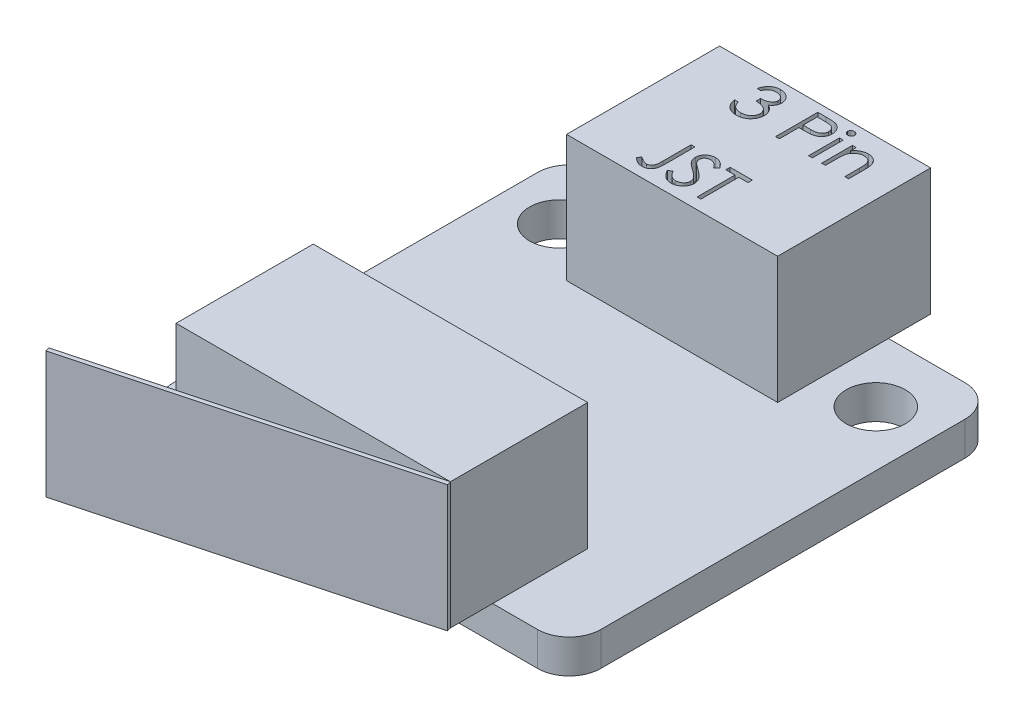
from build123d import *

# Parameters (mm, degrees)
SKETCH1_R           = 1.4
BOSS_EXTRUDE1_DEPTH = 1.6
SKETCH2_W           = 13
SKETCH2_H           = 4.5
SKETCH2_W_2         = 10
SKETCH2_H_2         = 2
SKETCH2_H_3         = 5.25
BOSS_EXTRUDE2_DEPTH = 6
SKETCH3_W           = 0.17948718
SKETCH3_H           = 1.461538462
CUT_EXTRUDE1_DEPTH  = 1


with BuildPart() as part:
    # Sketch1 → Boss-Extrude1 (new body)
    with BuildSketch(Plane(origin=(0, 0, 0), x_dir=(1, 0, 0), z_dir=(0, 1, 0))):
        with BuildLine():
            Line((-8.625, -10.125), (8.625, -10.125))
            ThreePointArc((8.625, -10.125), (9.685660172, -9.685660172), (10.125, -8.625))
            Line((10.125, -8.625), (10.125, 8.625))
            ThreePointArc((10.125, 8.625), (9.685660172, 9.685660172), (8.625, 10.125))
            Line((8.625, 10.125), (-8.625, 10.125))
            ThreePointArc((-8.625, 10.125), (-9.685660172, 9.685660172), (-10.125, 8.625))
            Line((-10.125, 8.625), (-10.125, -8.625))
            ThreePointArc((-10.125, -8.625), (-9.685660172, -9.685660172), (-8.625, -10.125))
        make_face()
        with Locations((-7.5, 7.025)):
            Circle(SKETCH1_R, mode=Mode.SUBTRACT)
        with Locations((7.5, 7.025)):
            Circle(SKETCH1_R, mode=Mode.SUBTRACT)
    extrude(amount=BOSS_EXTRUDE1_DEPTH)

    # Sketch2 → Boss-Extrude2 (add)
    with BuildSketch(Plane(origin=(0, 1.6, 0), x_dir=(1, 0, 0), z_dir=(0, 1, 0))):
        with Locations((0, -7.875)):
            Rectangle(SKETCH2_W, SKETCH2_H)
        with Locations((0, 11.125)):
            Rectangle(SKETCH2_W_2, SKETCH2_H_2)
        with Locations((0, 7.5)):
            Rectangle(SKETCH2_W_2, SKETCH2_H_3)
        with Locations((0, -11.125)):
            Rectangle(SKETCH2_W, SKETCH2_H_2)
        Polygon((-8.448236191, -16.337423052), (6.551763809, -12.318185165), (6.5, -12.125), (-8.5, -16.144237886), align=None)
    extrude(amount=BOSS_EXTRUDE2_DEPTH)

    # Sketch3 → Cut-Extrude1 (cut)
    with BuildSketch(Plane(origin=(0, 7.6, 0), x_dir=(1, 0, 0), z_dir=(0, 1, 0))):
        with BuildLine():
            Line((-2.186584499, 11.272188245), (-2.366071678, 11.272188245))
            add(Edge.make_bspline(
                [(-2.366071678, 11.272188245), (-2.361209078, 11.292321093), (-2.351703092, 11.331679164), (-2.331875907, 11.387911884), (-2.310276333, 11.441125325), (-2.284339701, 11.490323081), (-2.256048985, 11.536493883), (-2.223636001, 11.578590526), (-2.188596159, 11.617683649), (-2.149839046, 11.652376927), (-2.109194096, 11.683792773), (-2.066088599, 11.71057852), (-2.021389803, 11.733620893), (-1.974788012, 11.752603882), (-1.926144486, 11.766904182), (-1.875898987, 11.777279499), (-1.823919844, 11.784017279), (-1.788635506, 11.784674857), (-1.770719114, 11.785008758)],
                knots=[0, 0, 0, 0, 6.2094e-05, 0.000121389, 0.000178681, 0.000234231, 0.000288038, 0.000340924, 0.000393396, 0.000445302, 0.000496746, 0.000547326, 0.000597318, 0.000647462, 0.000698039, 0.000749191, 0.00080127, 0.000854993, 0.000854993, 0.000854993, 0.000854993], degree=3))
            add(Edge.make_bspline(
                [(-1.770719114, 11.785008758), (-1.74461469, 11.784220626), (-1.692975255, 11.782661554), (-1.617110657, 11.768424733), (-1.543952475, 11.745896086), (-1.474301476, 11.714768242), (-1.409605229, 11.676375492), (-1.352041693, 11.630681357), (-1.302391116, 11.57856747), (-1.260737186, 11.521006005), (-1.228122901, 11.459488571), (-1.204073544, 11.396174195), (-1.189432584, 11.331213069), (-1.187535123, 11.287351766), (-1.186584499, 11.265377347)],
                knots=[0, 0, 0, 0, 7.8249e-05, 0.000154792, 0.000230699, 0.00030746, 0.000383109, 0.000455815, 0.000527226, 0.000598392, 0.000668292, 0.000735487, 0.000801106, 0.000866986, 0.000866986, 0.000866986, 0.000866986], degree=3))
            add(Edge.make_bspline(
                [(-1.186584499, 11.265377347), (-1.187249408, 11.244230607), (-1.188550532, 11.202849719), (-1.199598364, 11.142437435), (-1.218190514, 11.085499378), (-1.243944664, 11.031795857), (-1.277282693, 10.981667377), (-1.317667091, 10.935001153), (-1.365382898, 10.891590206), (-1.401542291, 10.866721936), (-1.420158217, 10.853919014)],
                knots=[0, 0, 0, 0, 6.3404e-05, 0.000124072, 0.000183492, 0.000242626, 0.000302185, 0.000363545, 0.000427363, 0.000495082, 0.000495082, 0.000495082, 0.000495082], degree=3))
            add(Edge.make_bspline(
                [(-1.420158217, 10.853919014), (-1.398882928, 10.843645773), (-1.356730429, 10.823291512), (-1.299272983, 10.783373936), (-1.247114197, 10.737284594), (-1.218026358, 10.701317364), (-1.203411422, 10.683245937)],
                knots=[0, 0, 0, 0, 7.0779e-05, 0.000140233, 0.000209172, 0.000278788, 0.000278788, 0.000278788, 0.000278788], degree=3))
            add(Edge.make_bspline(
                [(-1.203411422, 10.683245937), (-1.193787798, 10.670070079), (-1.174698143, 10.643934127), (-1.151134981, 10.601913312), (-1.129758344, 10.559426747), (-1.113101076, 10.515335657), (-1.100201723, 10.470151078), (-1.090981133, 10.423795423), (-1.085253053, 10.376230839), (-1.084432737, 10.344052279), (-1.084020396, 10.327877347)],
                knots=[0, 0, 0, 0, 4.8904e-05, 9.7008e-05, 0.000144311, 0.000191485, 0.000238152, 0.000285138, 0.000333143, 0.000381662, 0.000381662, 0.000381662, 0.000381662], degree=3))
            add(Edge.make_bspline(
                [(-1.084020396, 10.327877347), (-1.085045832, 10.299871792), (-1.087091879, 10.243992477), (-1.105379922, 10.161435493), (-1.133730345, 10.080735206), (-1.173991451, 10.003549584), (-1.223058599, 9.931332223), (-1.281434213, 9.866717189), (-1.348455018, 9.81117513), (-1.423201103, 9.764769285), (-1.504182319, 9.72767333), (-1.590796943, 9.701926219), (-1.681796974, 9.685157077), (-1.744201144, 9.683358866), (-1.775927447, 9.682444655)],
                knots=[0, 0, 0, 0, 8.3922e-05, 0.000167448, 0.000252476, 0.000339918, 0.00042782, 0.000513763, 0.00060025, 0.000688074, 0.000777001, 0.000866606, 0.000958558, 0.001053653, 0.001053653, 0.001053653, 0.001053653], degree=3))
            add(Edge.make_bspline(
                [(-1.775927447, 9.682444655), (-1.797309905, 9.682940777), (-1.83938345, 9.683916979), (-1.901236878, 9.690590466), (-1.960277849, 9.70277904), (-2.016586191, 9.719180929), (-2.070211926, 9.73997621), (-2.120991415, 9.765872609), (-2.169237068, 9.796336324), (-2.214493612, 9.831726946), (-2.25675565, 9.871316283), (-2.294900064, 9.915807146), (-2.329562803, 9.964377091), (-2.359815739, 10.017590266), (-2.387036855, 10.074758984), (-2.409425973, 10.136615269), (-2.429132012, 10.202606139), (-2.438293992, 10.248593419), (-2.442994755, 10.272188245)],
                knots=[0, 0, 0, 0, 6.4148e-05, 0.000126221, 0.000186329, 0.000244775, 0.000301988, 0.000358608, 0.000415515, 0.000472897, 0.000530714, 0.000588945, 0.00064842, 0.000709443, 0.000772349, 0.000838139, 0.0009066, 0.000978738, 0.000978738, 0.000978738, 0.000978738], degree=3))
            Line((-2.442994755, 10.272188245), (-2.263507576, 10.272188245))
            add(Edge.make_bspline(
                [(-2.263507576, 10.272188245), (-2.258831409, 10.256788809), (-2.249735859, 10.226835568), (-2.234253403, 10.183726822), (-2.21661439, 10.144207934), (-2.197691785, 10.107989007), (-2.177818388, 10.074713349), (-2.155581288, 10.045260852), (-2.13262749, 10.018337879), (-2.115325003, 10.00316953), (-2.106856935, 9.995745937)],
                knots=[0, 0, 0, 0, 4.8278e-05, 9.3906e-05, 0.00013731, 0.000177989, 0.000216467, 0.000253406, 0.000288608, 0.00032235, 0.00032235, 0.00032235, 0.00032235], degree=3))
            add(Edge.make_bspline(
                [(-2.106856935, 9.995745937), (-2.095658891, 9.987112603), (-2.073297369, 9.969872585), (-2.03685838, 9.947871655), (-1.998535588, 9.928808212), (-1.957498631, 9.9142461), (-1.914633048, 9.901916008), (-1.869245982, 9.89384714), (-1.821737858, 9.888311042), (-1.789299136, 9.88782251), (-1.772722319, 9.88757286)],
                knots=[0, 0, 0, 0, 4.2389e-05, 8.4646e-05, 0.00012747, 0.000170564, 0.000215086, 0.000261134, 0.000308695, 0.000358401, 0.000358401, 0.000358401, 0.000358401], degree=3))
            add(Edge.make_bspline(
                [(-1.772722319, 9.88757286), (-1.754006032, 9.887924806), (-1.717407948, 9.888613006), (-1.664005171, 9.894941981), (-1.613200916, 9.90415936), (-1.565559244, 9.91839535), (-1.520456097, 9.935984408), (-1.478523725, 9.958069211), (-1.439211665, 9.983980481), (-1.403023433, 10.013431429), (-1.370483143, 10.045672283), (-1.341831993, 10.079394038), (-1.317475043, 10.114454512), (-1.297827284, 10.151047724), (-1.282312684, 10.18902214), (-1.271750855, 10.228484329), (-1.264407132, 10.269111338), (-1.263809068, 10.296727892), (-1.263507576, 10.310649783)],
                knots=[0, 0, 0, 0, 5.6126e-05, 0.000109749, 0.000161137, 0.000210833, 0.00025867, 0.000306159, 0.000352718, 0.000399709, 0.000445888, 0.000489953, 0.000532294, 0.000573701, 0.000614323, 0.000655048, 0.000696082, 0.000737797, 0.000737797, 0.000737797, 0.000737797], degree=3))
            add(Edge.make_bspline(
                [(-1.263507576, 10.310649783), (-1.264382034, 10.329284834), (-1.266126598, 10.36646221), (-1.279445787, 10.421157967), (-1.301353709, 10.47385706), (-1.332023716, 10.523660368), (-1.369358418, 10.569818026), (-1.412995507, 10.611001731), (-1.463297352, 10.64498464), (-1.50959442, 10.668463872), (-1.550603081, 10.684485058), (-1.585697586, 10.695156466), (-1.624987074, 10.704192841), (-1.667996416, 10.712599853), (-1.715049683, 10.719754909), (-1.766095647, 10.725721661), (-1.821144654, 10.73049597), (-1.859253892, 10.732628024), (-1.878892191, 10.733726706)],
                knots=[0, 0, 0, 0, 5.5863e-05, 0.000111448, 0.000167846, 0.000226457, 0.000286274, 0.000345516, 0.000405747, 0.000467742, 0.00050085, 0.000537728, 0.000577668, 0.000621748, 0.000669174, 0.000720409, 0.000775906, 0.000834911, 0.000834911, 0.000834911, 0.000834911], degree=3))
            Line((-1.878892191, 10.733726706), (-1.878892191, 10.938854911))
            add(Edge.make_bspline(
                [(-1.878892191, 10.938854911), (-1.854148668, 10.939274799), (-1.805682184, 10.940097256), (-1.734885438, 10.950044691), (-1.667186403, 10.96380505), (-1.604085407, 10.984882302), (-1.546571857, 11.009362472), (-1.496674942, 11.037849449), (-1.455093715, 11.06951502), (-1.422030245, 11.10484794), (-1.3971564, 11.142742252), (-1.378969659, 11.182237485), (-1.368226615, 11.223679806), (-1.36679252, 11.251962473), (-1.366071678, 11.266178629)],
                knots=[0, 0, 0, 0, 7.4172e-05, 0.000145284, 0.00021412, 0.000281142, 0.000344481, 0.000401381, 0.000453069, 0.000500694, 0.000545808, 0.000588481, 0.000630653, 0.000673274, 0.000673274, 0.000673274, 0.000673274], degree=3))
            add(Edge.make_bspline(
                [(-1.366071678, 11.266178629), (-1.366308484, 11.276623055), (-1.366779599, 11.297401745), (-1.372720901, 11.327758927), (-1.381648924, 11.357188039), (-1.393923055, 11.385563931), (-1.41035174, 11.412689801), (-1.430012304, 11.438796915), (-1.453422647, 11.463736217), (-1.480248617, 11.486982114), (-1.509055362, 11.509135964), (-1.540626662, 11.527943757), (-1.574010591, 11.544026649), (-1.609244108, 11.557289222), (-1.646441554, 11.567265958), (-1.685428158, 11.574429296), (-1.726278263, 11.578907956), (-1.754147824, 11.579552765), (-1.768315268, 11.579880552)],
                knots=[0, 0, 0, 0, 3.1291e-05, 6.2252e-05, 9.2415e-05, 0.000123453, 0.000154716, 0.000187329, 0.000221343, 0.00025711, 0.000293729, 0.000330214, 0.000367127, 0.000404781, 0.000442976, 0.000482502, 0.000523604, 0.000566103, 0.000566103, 0.000566103, 0.000566103], degree=3))
            add(Edge.make_bspline(
                [(-1.768315268, 11.579880552), (-1.79108765, 11.579085488), (-1.835567408, 11.577532543), (-1.899690217, 11.563930821), (-1.959301265, 11.542229059), (-2.004866218, 11.516324477), (-2.038513403, 11.4907528), (-2.062557367, 11.468420008), (-2.086169088, 11.443601252), (-2.107795189, 11.414767895), (-2.129666033, 11.383872586), (-2.149577211, 11.349344768), (-2.168925606, 11.312085114), (-2.180584206, 11.285744751), (-2.186584499, 11.272188245)],
                knots=[0, 0, 0, 0, 6.8251e-05, 0.000133311, 0.000195677, 0.000257943, 0.000289675, 0.000322285, 0.000356299, 0.000392281, 0.000430289, 0.000469798, 0.000511728, 0.000556192, 0.000556192, 0.000556192, 0.000556192], degree=3))
        make_face()
        with BuildLine():
            Line((0.044184732, 11.733726706), (0.436412296, 11.733726706))
            add(Edge.make_bspline(
                [(0.436412296, 11.733726706), (0.463389957, 11.733697051), (0.515080353, 11.733640231), (0.589203242, 11.731917519), (0.656523088, 11.729616552), (0.716894735, 11.726426899), (0.770503933, 11.722657419), (0.817108105, 11.717370539), (0.857073565, 11.71185037), (0.881020108, 11.706238138), (0.891941142, 11.703678629)],
                knots=[0, 0, 0, 0, 8.093e-05, 0.000155066, 0.000222417, 0.000282999, 0.000336434, 0.000383598, 0.000423714, 0.000457349, 0.000457349, 0.000457349, 0.000457349], degree=3))
            add(Edge.make_bspline(
                [(0.891941142, 11.703678629), (0.905766019, 11.699894658), (0.933090006, 11.69241588), (0.97246203, 11.677436609), (1.009921371, 11.659675372), (1.045596547, 11.639433121), (1.079049166, 11.61584137), (1.110778332, 11.589856445), (1.140504035, 11.560878406), (1.168059116, 11.529232269), (1.193364715, 11.495449292), (1.215153105, 11.459025161), (1.233397235, 11.420572987), (1.249044818, 11.380119518), (1.260306792, 11.337325047), (1.268790735, 11.292486926), (1.274175665, 11.24560996), (1.274691415, 11.21357575), (1.274953963, 11.197268373)],
                knots=[0, 0, 0, 0, 4.2981e-05, 8.4949e-05, 0.000126168, 0.000167265, 0.000207832, 0.000248819, 0.000290184, 0.000332208, 0.000374596, 0.000416646, 0.000459295, 0.000502155, 0.00054657, 0.00059183, 0.000638993, 0.000687898, 0.000687898, 0.000687898, 0.000687898], degree=3))
            add(Edge.make_bspline(
                [(1.274953963, 11.197268373), (1.274713149, 11.180823929), (1.27424198, 11.148649264), (1.268586959, 11.101579099), (1.260969707, 11.056597162), (1.249257106, 11.01380319), (1.233916721, 10.973451321), (1.215921262, 10.934924903), (1.194216388, 10.898879376), (1.169276485, 10.865183881), (1.141532717, 10.833806788), (1.111102467, 10.804975477), (1.078108585, 10.778858712), (1.042655929, 10.755397944), (1.004398873, 10.735137213), (0.963917642, 10.716990182), (0.920860375, 10.701749576), (0.891064653, 10.693732398), (0.875915501, 10.689656193)],
                knots=[0, 0, 0, 0, 4.9305e-05, 9.6468e-05, 0.00014205, 0.000186079, 0.000229313, 0.000271428, 0.000313478, 0.000355306, 0.000397028, 0.000438971, 0.000480893, 0.000523119, 0.000566318, 0.000610617, 0.000656109, 0.000703161, 0.000703161, 0.000703161, 0.000703161], degree=3))
            add(Edge.make_bspline(
                [(0.875915501, 10.689656193), (0.863385596, 10.686991633), (0.835925581, 10.681152093), (0.790701168, 10.674632975), (0.738046662, 10.669068632), (0.67803393, 10.664896553), (0.610716842, 10.661324914), (0.53605898, 10.658486003), (0.453913793, 10.656926087), (0.39661594, 10.656845634), (0.366700758, 10.656803629)],
                knots=[0, 0, 0, 0, 3.8422e-05, 8.4204e-05, 0.000136987, 0.000197244, 0.000264648, 0.00033922, 0.000421367, 0.000511112, 0.000511112, 0.000511112, 0.000511112], degree=3))
            Line((0.366700758, 10.656803629), (0.223671912, 10.656803629))
            Line((0.223671912, 10.656803629), (0.223671912, 9.733726706))
            Line((0.223671912, 9.733726706), (0.044184732, 9.733726706))
            Line((0.044184732, 9.733726706), (0.044184732, 11.733726706))
        make_face()
        with BuildLine():
            Line((0.223671912, 11.528598501), (0.223671912, 10.861931834))
            Line((0.223671912, 10.861931834), (0.573832168, 10.857524783))
            add(Edge.make_bspline(
                [(0.573832168, 10.857524783), (0.590929268, 10.857515947), (0.623934868, 10.857498888), (0.67161271, 10.859776159), (0.715846589, 10.862405035), (0.756500632, 10.866254134), (0.793593166, 10.871694852), (0.827186039, 10.877187274), (0.857018772, 10.885133196), (0.891932602, 10.895832092), (0.930837372, 10.914079301), (0.973161685, 10.940564953), (1.009030592, 10.974325357), (1.040069619, 11.012284118), (1.064701549, 11.054512192), (1.082733545, 11.099694442), (1.093328492, 11.147367499), (1.094749174, 11.179989292), (1.095466783, 11.196467091)],
                knots=[0, 0, 0, 0, 5.1284e-05, 9.9002e-05, 0.000143162, 0.000184223, 0.000221448, 0.000255634, 0.000286243, 0.000313992, 0.000365087, 0.000414652, 0.000463136, 0.000512129, 0.000561328, 0.000609166, 0.000657575, 0.000706986, 0.000706986, 0.000706986, 0.000706986], degree=3))
            add(Edge.make_bspline(
                [(1.095466783, 11.196467091), (1.094745271, 11.212546241), (1.093310994, 11.244509603), (1.082650501, 11.291354609), (1.064736607, 11.336060725), (1.039904267, 11.377759631), (1.009766479, 11.415581805), (0.974738283, 11.448437306), (0.934902133, 11.474849708), (0.897846001, 11.491897297), (0.864931038, 11.502306026), (0.836341347, 11.509588792), (0.804060961, 11.515403424), (0.768079373, 11.520111712), (0.728675468, 11.524142261), (0.685510716, 11.526877105), (0.638748635, 11.528477937), (0.606285451, 11.52855734), (0.589457168, 11.528598501)],
                knots=[0, 0, 0, 0, 4.8212e-05, 9.5839e-05, 0.000143305, 0.000192158, 0.0002409, 0.000287958, 0.000335627, 0.000383673, 0.000409773, 0.000439118, 0.000472122, 0.000508102, 0.000547967, 0.000590927, 0.00063783, 0.000688312, 0.000688312, 0.000688312, 0.000688312], degree=3))
            Line((0.589457168, 11.528598501), (0.223671912, 11.528598501))
        make_face(mode=Mode.SUBTRACT)
        with BuildLine():
            add(Edge.make_bspline(
                [(1.697229604, 11.810649783), (1.708367499, 11.810133125), (1.730177636, 11.809121408), (1.761716646, 11.800457707), (1.790434938, 11.785772172), (1.815907929, 11.766069498), (1.83776615, 11.742898387), (1.853069413, 11.715892119), (1.862905068, 11.686715754), (1.864092813, 11.666364275), (1.864697553, 11.656002347)],
                knots=[0, 0, 0, 0, 3.3371e-05, 6.5347e-05, 9.724e-05, 0.000129534, 0.000161577, 0.000192089, 0.00022199, 0.000253006, 0.000253006, 0.000253006, 0.000253006], degree=3))
            add(Edge.make_bspline(
                [(1.864697553, 11.656002347), (1.864079176, 11.645909403), (1.862856717, 11.625956845), (1.85307701, 11.59728629), (1.837635731, 11.570655271), (1.815921945, 11.547529151), (1.790431224, 11.527837368), (1.761717632, 11.513148946), (1.730177376, 11.50448601), (1.708367411, 11.503474188), (1.697229604, 11.502957475)],
                knots=[0, 0, 0, 0, 3.0219e-05, 5.9738e-05, 8.9904e-05, 0.000121948, 0.000154241, 0.000186134, 0.00021811, 0.000251481, 0.000251481, 0.000251481, 0.000251481], degree=3))
            add(Edge.make_bspline(
                [(1.697229604, 11.502957475), (1.686219161, 11.503454458), (1.664788772, 11.504421771), (1.633722005, 11.513318924), (1.605248583, 11.527842394), (1.579725913, 11.547400214), (1.558451517, 11.570797298), (1.542966759, 11.597270038), (1.533209638, 11.625960983), (1.531984136, 11.645910793), (1.531364219, 11.656002347)],
                knots=[0, 0, 0, 0, 3.2972e-05, 6.4176e-05, 9.6069e-05, 0.000128362, 0.000160137, 0.000190302, 0.000219822, 0.000250041, 0.000250041, 0.000250041, 0.000250041], degree=3))
            add(Edge.make_bspline(
                [(1.531364219, 11.656002347), (1.531970554, 11.666362833), (1.533161435, 11.68671148), (1.542974073, 11.715908642), (1.558322534, 11.742755214), (1.579739999, 11.766198357), (1.605244834, 11.785767176), (1.633722974, 11.800287737), (1.664788516, 11.809185646), (1.686219074, 11.810152854), (1.697229604, 11.810649783)],
                knots=[0, 0, 0, 0, 3.1015e-05, 6.0916e-05, 9.1428e-05, 0.000123203, 0.000155496, 0.000187389, 0.000218593, 0.000251565, 0.000251565, 0.000251565, 0.000251565], degree=3))
        make_face()
        with Locations((1.698030886, 10.464495937)):
            Rectangle(SKETCH3_W, SKETCH3_H)
        with BuildLine():
            Line((2.223671912, 11.195265168), (2.403159091, 11.195265168))
            Line((2.403159091, 11.195265168), (2.403159091, 10.931643373))
            add(Edge.make_bspline(
                [(2.403159091, 10.931643373), (2.422323454, 10.9555535), (2.459512569, 11.001951937), (2.521446474, 11.062935122), (2.586900131, 11.113189536), (2.655472704, 11.153248847), (2.727257282, 11.183446919), (2.801816293, 11.205256023), (2.879596125, 11.218333068), (2.932490089, 11.220041771), (2.959248835, 11.220906193)],
                knots=[0, 0, 0, 0, 9.1873e-05, 0.000178282, 0.000260017, 0.000338833, 0.00041585, 0.000493062, 0.000571441, 0.00065169, 0.00065169, 0.00065169, 0.00065169], degree=3))
            add(Edge.make_bspline(
                [(2.959248835, 11.220906193), (2.986294911, 11.219908939), (3.039230607, 11.217957071), (3.116303785, 11.202518962), (3.188288581, 11.176150245), (3.254928328, 11.140029062), (3.315001021, 11.095111077), (3.367758079, 11.042780916), (3.41139422, 10.982588868), (3.440649856, 10.926747065), (3.459921655, 10.877210611), (3.472054419, 10.834783897), (3.482357837, 10.787516382), (3.491290265, 10.735550902), (3.497334329, 10.678523365), (3.502101352, 10.616667541), (3.505517749, 10.550003466), (3.505653296, 10.503896822), (3.505723194, 10.480120937)],
                knots=[0, 0, 0, 0, 8.1097e-05, 0.000158726, 0.000234646, 0.000310299, 0.000385299, 0.000458956, 0.000532359, 0.000607446, 0.0006474, 0.000691647, 0.000739665, 0.000792489, 0.00084974, 0.000911626, 0.00097861, 0.001049928, 0.001049928, 0.001049928, 0.001049928], degree=3))
            Line((3.505723194, 10.480120937), (3.505723194, 9.733726706))
            Line((3.505723194, 9.733726706), (3.326236014, 9.733726706))
            Line((3.326236014, 9.733726706), (3.326236014, 10.421226706))
            add(Edge.make_bspline(
                [(3.326236014, 10.421226706), (3.32612561, 10.441125246), (3.325914424, 10.479187767), (3.325248341, 10.533684351), (3.323642737, 10.583105253), (3.321386558, 10.62733232), (3.318084255, 10.666323084), (3.314642751, 10.700156957), (3.310434193, 10.728790981), (3.306683957, 10.746028171), (3.30500204, 10.753758758)],
                knots=[0, 0, 0, 0, 5.9697e-05, 0.00011419, 0.000163495, 0.000208031, 0.000247025, 0.000280871, 0.000310052, 0.000333782, 0.000333782, 0.000333782, 0.000333782], degree=3))
            add(Edge.make_bspline(
                [(3.30500204, 10.753758758), (3.298930307, 10.776450863), (3.287244101, 10.820126146), (3.25836754, 10.879368633), (3.221902293, 10.929767598), (3.177389237, 10.971011438), (3.125258336, 11.003109059), (3.065654255, 11.025379891), (2.999152174, 11.039309187), (2.952378241, 11.04069612), (2.927998835, 11.041419014)],
                knots=[0, 0, 0, 0, 7.0341e-05, 0.000135384, 0.000196446, 0.000255981, 0.000316244, 0.000378893, 0.000445995, 0.000519045, 0.000519045, 0.000519045, 0.000519045], degree=3))
            add(Edge.make_bspline(
                [(2.927998835, 11.041419014), (2.913560158, 11.041147011), (2.884986391, 11.040608725), (2.842614978, 11.035207983), (2.801515451, 11.02637458), (2.761275331, 11.014449644), (2.722699449, 10.998071205), (2.684548426, 10.979482993), (2.648258846, 10.956312586), (2.613056905, 10.930489374), (2.580306729, 10.901872684), (2.549833393, 10.871675821), (2.52266881, 10.839518333), (2.498058138, 10.805918363), (2.476813416, 10.770414456), (2.458268795, 10.733349138), (2.442534112, 10.694673624), (2.434715431, 10.667830732), (2.430803322, 10.654399783)],
                knots=[0, 0, 0, 0, 4.3299e-05, 8.5687e-05, 0.000127884, 0.000169329, 0.000211366, 0.000253471, 0.000296491, 0.000340322, 0.000384344, 0.000426838, 0.000468903, 0.000510495, 0.000551652, 0.000592861, 0.000634747, 0.000676692, 0.000676692, 0.000676692, 0.000676692], degree=3))
            add(Edge.make_bspline(
                [(2.430803322, 10.654399783), (2.428552094, 10.644539667), (2.423651289, 10.62307471), (2.418358043, 10.587849328), (2.413553715, 10.547100771), (2.409532595, 10.500876589), (2.407072357, 10.449014947), (2.404389845, 10.391737325), (2.403413239, 10.328815332), (2.403246179, 10.28500865), (2.403159091, 10.262172219)],
                knots=[0, 0, 0, 0, 3.0333e-05, 6.6032e-05, 0.000106782, 0.000153428, 0.000205187, 0.000262529, 0.000325441, 0.000393952, 0.000393952, 0.000393952, 0.000393952], degree=3))
            Line((2.403159091, 10.262172219), (2.403159091, 9.733726706))
            Line((2.403159091, 9.733726706), (2.223671912, 9.733726706))
            Line((2.223671912, 9.733726706), (2.223671912, 11.195265168))
        make_face()
        with BuildLine():
            Line((-1.622481935, 7.400393373), (-1.442994755, 7.400393373))
            Line((-1.442994755, 7.400393373), (-1.442994755, 6.049832475))
            add(Edge.make_bspline(
                [(-1.442994755, 6.049832475), (-1.443174137, 6.024858092), (-1.443518573, 5.976904229), (-1.445412522, 5.907833431), (-1.448917366, 5.844764467), (-1.454023087, 5.787553926), (-1.460834649, 5.736381037), (-1.468629522, 5.690850399), (-1.478065407, 5.651342009), (-1.492274817, 5.606978948), (-1.515574216, 5.558325346), (-1.550641095, 5.505779545), (-1.594202693, 5.459817596), (-1.644660426, 5.419901754), (-1.702455297, 5.388097621), (-1.766397136, 5.365266091), (-1.836092329, 5.351339887), (-1.884434736, 5.349869084), (-1.909340909, 5.349111322)],
                knots=[0, 0, 0, 0, 7.4924e-05, 0.000143864, 0.000207267, 0.000264396, 0.000316129, 0.000362105, 0.000402917, 0.000437886, 0.000501687, 0.000564025, 0.000626665, 0.000690864, 0.000756317, 0.000823611, 0.000893855, 0.000968504, 0.000968504, 0.000968504, 0.000968504], degree=3))
            add(Edge.make_bspline(
                [(-1.909340909, 5.349111322), (-1.928745685, 5.349728813), (-1.96778938, 5.350971245), (-2.025898356, 5.361097938), (-2.083842343, 5.376707106), (-2.141928885, 5.399565732), (-2.201305594, 5.430654645), (-2.262776649, 5.471331683), (-2.327132759, 5.521521127), (-2.369523208, 5.55982841), (-2.391712704, 5.579880552)],
                knots=[0, 0, 0, 0, 5.8181e-05, 0.000117065, 0.000176449, 0.000237977, 0.000303921, 0.000377151, 0.000458813, 0.000548513, 0.000548513, 0.000548513, 0.000548513], degree=3))
            Line((-2.391712704, 5.579880552), (-2.285943473, 5.733726706))
            add(Edge.make_bspline(
                [(-2.285943473, 5.733726706), (-2.261541942, 5.716899623), (-2.21546867, 5.685127895), (-2.147751847, 5.644255552), (-2.087753474, 5.6092126), (-2.048506075, 5.591354155), (-2.030334499, 5.583085681)],
                knots=[0, 0, 0, 0, 8.8895e-05, 0.000167846, 0.000237269, 0.000297126, 0.000297126, 0.000297126, 0.000297126], degree=3))
            add(Edge.make_bspline(
                [(-2.030334499, 5.583085681), (-2.019314892, 5.578765991), (-1.99770299, 5.570294117), (-1.964660087, 5.560839318), (-1.93180578, 5.555672226), (-1.910024241, 5.554711465), (-1.899324883, 5.554239527)],
                knots=[0, 0, 0, 0, 3.5497e-05, 6.9617e-05, 0.00010288, 0.000134994, 0.000134994, 0.000134994, 0.000134994], degree=3))
            add(Edge.make_bspline(
                [(-1.899324883, 5.554239527), (-1.885506147, 5.554823947), (-1.858191601, 5.555979129), (-1.81849789, 5.566178715), (-1.780521872, 5.581746946), (-1.745624925, 5.604541971), (-1.713461846, 5.63164564), (-1.686923089, 5.664420502), (-1.664798949, 5.700743921), (-1.651484839, 5.735127609), (-1.643002112, 5.766485684), (-1.637618325, 5.795304618), (-1.632910519, 5.828996892), (-1.628806775, 5.86760272), (-1.626404221, 5.911199396), (-1.623708636, 5.959658906), (-1.622734201, 6.013103427), (-1.622568589, 6.050366829), (-1.622481935, 6.069864527)],
                knots=[0, 0, 0, 0, 4.139e-05, 8.1813e-05, 0.000122217, 0.000164006, 0.000206332, 0.000247883, 0.000289933, 0.000333456, 0.000357948, 0.000387334, 0.00042133, 0.000459999, 0.000503759, 0.000552296, 0.000605595, 0.00066409, 0.00066409, 0.00066409, 0.00066409], degree=3))
            Line((-1.622481935, 6.069864527), (-1.622481935, 7.400393373))
        make_face()
        with BuildLine():
            Line((-1.135302447, 5.786210681), (-0.966231935, 5.88757286))
            add(Edge.make_bspline(
                [(-0.966231935, 5.88757286), (-0.950507228, 5.861250354), (-0.920379296, 5.810817449), (-0.870121376, 5.742669998), (-0.818045427, 5.684748765), (-0.763765808, 5.637390704), (-0.707613838, 5.600105626), (-0.64922295, 5.57370435), (-0.588789915, 5.557238079), (-0.547662017, 5.555238029), (-0.52712937, 5.554239527)],
                knots=[0, 0, 0, 0, 9.1943e-05, 0.00017616, 0.000253587, 0.00032516, 0.000391722, 0.000455019, 0.000516726, 0.000578245, 0.000578245, 0.000578245, 0.000578245], degree=3))
            add(Edge.make_bspline(
                [(-0.52712937, 5.554239527), (-0.509594022, 5.554727911), (-0.474830151, 5.555696134), (-0.423651727, 5.564999449), (-0.37394784, 5.579292095), (-0.326742904, 5.599761198), (-0.282688267, 5.624526047), (-0.24405587, 5.654438149), (-0.210658091, 5.687927409), (-0.183338597, 5.725288926), (-0.162378577, 5.765470154), (-0.146268823, 5.806713555), (-0.137328781, 5.849667022), (-0.135982065, 5.878587287), (-0.135302447, 5.893181834)],
                knots=[0, 0, 0, 0, 5.2559e-05, 0.000104198, 0.000155544, 0.000207414, 0.000258201, 0.000306763, 0.000353508, 0.000399665, 0.000445008, 0.000489133, 0.000532114, 0.000575902, 0.000575902, 0.000575902, 0.000575902], degree=3))
            add(Edge.make_bspline(
                [(-0.135302447, 5.893181834), (-0.136144911, 5.909833749), (-0.137857515, 5.943684657), (-0.152332647, 5.993627315), (-0.175103645, 6.043051641), (-0.19611087, 6.073623793), (-0.207017191, 6.089495937)],
                knots=[0, 0, 0, 0, 4.9875e-05, 0.000101388, 0.000154805, 0.000212482, 0.000212482, 0.000212482, 0.000212482], degree=3))
            add(Edge.make_bspline(
                [(-0.207017191, 6.089495937), (-0.215971828, 6.100951265), (-0.234770967, 6.125000293), (-0.267089546, 6.16079757), (-0.30501304, 6.197722381), (-0.347243643, 6.237184699), (-0.395319693, 6.277349154), (-0.447735416, 6.320131027), (-0.50582905, 6.363903357), (-0.546571619, 6.393259109), (-0.567594114, 6.408406193)],
                knots=[0, 0, 0, 0, 4.3611e-05, 9.1556e-05, 0.000144533, 0.00020237, 0.000264903, 0.000332417, 0.000405335, 0.000483068, 0.000483068, 0.000483068, 0.000483068], degree=3))
            add(Edge.make_bspline(
                [(-0.567594114, 6.408406193), (-0.588636398, 6.423393958), (-0.628867641, 6.452049422), (-0.685129688, 6.494577584), (-0.73544081, 6.533459795), (-0.779577391, 6.569062088), (-0.817520018, 6.601389291), (-0.849567681, 6.63013097), (-0.874904, 6.656064434), (-0.888992903, 6.672888057), (-0.895318473, 6.68044145)],
                knots=[0, 0, 0, 0, 7.7499e-05, 0.000148172, 0.000211562, 0.000268251, 0.000318269, 0.000361092, 0.000397358, 0.000426908, 0.000426908, 0.000426908, 0.000426908], degree=3))
            add(Edge.make_bspline(
                [(-0.895318473, 6.68044145), (-0.904159927, 6.692213471), (-0.921547834, 6.71536473), (-0.944499837, 6.751550363), (-0.96400793, 6.788592229), (-0.979300692, 6.826589866), (-0.992178531, 6.865009825), (-1.000840206, 6.904353394), (-1.006263861, 6.944444033), (-1.006819282, 6.971423177), (-1.007097319, 6.984928629)],
                knots=[0, 0, 0, 0, 4.4154e-05, 8.6835e-05, 0.000128409, 0.000169553, 0.000209589, 0.000249829, 0.00029023, 0.000330726, 0.000330726, 0.000330726, 0.000330726], degree=3))
            add(Edge.make_bspline(
                [(-1.007097319, 6.984928629), (-1.006351485, 7.0060885), (-1.00487576, 7.047955965), (-0.992395464, 7.10911644), (-0.972696668, 7.167508678), (-0.945099589, 7.222554583), (-0.909523959, 7.272820858), (-0.868354831, 7.318885708), (-0.819319696, 7.357610612), (-0.765518197, 7.391446074), (-0.706628841, 7.41792946), (-0.644919753, 7.437907163), (-0.580292855, 7.449226739), (-0.536519635, 7.450851176), (-0.514308858, 7.451675424)],
                knots=[0, 0, 0, 0, 6.3428e-05, 0.0001255, 0.000186441, 0.000247897, 0.000309471, 0.000370729, 0.000432548, 0.00049625, 0.000560973, 0.00062572, 0.000690402, 0.000757029, 0.000757029, 0.000757029, 0.000757029], degree=3))
            add(Edge.make_bspline(
                [(-0.514308858, 7.451675424), (-0.4907408, 7.450862538), (-0.443871457, 7.449245965), (-0.374929048, 7.435190233), (-0.308551495, 7.411932707), (-0.255155344, 7.385539188), (-0.213365195, 7.359178379), (-0.181495062, 7.335167051), (-0.149199376, 7.307524131), (-0.11621763, 7.276175991), (-0.083108682, 7.24083499), (-0.049380995, 7.201743168), (-0.014955698, 7.159139422), (0.007190508, 7.128725421), (0.018543706, 7.113133758)],
                knots=[0, 0, 0, 0, 7.065e-05, 0.000140501, 0.000210062, 0.000281193, 0.00031865, 0.000358154, 0.000400784, 0.000446125, 0.00049459, 0.000545998, 0.000600997, 0.000658851, 0.000658851, 0.000658851, 0.000658851], degree=3))
            Line((0.018543706, 7.113133758), (-0.143715909, 6.990136963))
            add(Edge.make_bspline(
                [(-0.143715909, 6.990136963), (-0.153513585, 7.002759071), (-0.172381617, 7.027066302), (-0.201027038, 7.061107054), (-0.228026266, 7.092202185), (-0.254626494, 7.119210829), (-0.279422855, 7.143612048), (-0.303489736, 7.164503338), (-0.326480794, 7.182089393), (-0.355461886, 7.200857141), (-0.391872011, 7.219460857), (-0.43757746, 7.235203188), (-0.485341046, 7.244663223), (-0.517872264, 7.245914016), (-0.534340909, 7.246547219)],
                knots=[0, 0, 0, 0, 4.793e-05, 9.2302e-05, 0.000133459, 0.000171424, 0.000205991, 0.000237801, 0.000266968, 0.00029275, 0.000341307, 0.0003892, 0.000437365, 0.000486748, 0.000486748, 0.000486748, 0.000486748], degree=3))
            add(Edge.make_bspline(
                [(-0.534340909, 7.246547219), (-0.555001779, 7.245854819), (-0.59484432, 7.244519591), (-0.651410169, 7.229936742), (-0.702320984, 7.206975679), (-0.746065307, 7.174795692), (-0.782486436, 7.13666941), (-0.808832413, 7.092795779), (-0.82468965, 7.044348691), (-0.826624667, 7.010553459), (-0.82761014, 6.993342091)],
                knots=[0, 0, 0, 0, 6.1856e-05, 0.000119283, 0.00017396, 0.000228453, 0.000281174, 0.000331125, 0.000380792, 0.000432338, 0.000432338, 0.000432338, 0.000432338], degree=3))
            add(Edge.make_bspline(
                [(-0.82761014, 6.993342091), (-0.827385496, 6.98262696), (-0.826935841, 6.961179178), (-0.820664528, 6.929492651), (-0.812607769, 6.897886171), (-0.79984055, 6.866501838), (-0.782214663, 6.834790776), (-0.759068848, 6.802206926), (-0.729918384, 6.768463092), (-0.707588663, 6.746516022), (-0.695799242, 6.734928629)],
                knots=[0, 0, 0, 0, 3.2091e-05, 6.4235e-05, 9.6598e-05, 0.000129854, 0.000165538, 0.000205219, 0.000249544, 0.000299122, 0.000299122, 0.000299122, 0.000299122], degree=3))
            add(Edge.make_bspline(
                [(-0.695799242, 6.734928629), (-0.691421315, 6.731021757), (-0.681020363, 6.721739924), (-0.662005548, 6.706544335), (-0.636895377, 6.687799894), (-0.606345548, 6.664607142), (-0.56979277, 6.637703449), (-0.527233024, 6.607432813), (-0.479140719, 6.572812551), (-0.44501391, 6.548608242), (-0.426969114, 6.53581004)],
                knots=[0, 0, 0, 0, 1.7601e-05, 4.1816e-05, 7.2986e-05, 0.000111608, 0.000156882, 0.000209138, 0.000268286, 0.000334654, 0.000334654, 0.000334654, 0.000334654], degree=3))
            add(Edge.make_bspline(
                [(-0.426969114, 6.53581004), (-0.405262878, 6.520014977), (-0.36323176, 6.489430027), (-0.303427429, 6.44347821), (-0.249202395, 6.398536628), (-0.200366279, 6.354892281), (-0.156436617, 6.312876228), (-0.117900777, 6.271982982), (-0.084366102, 6.232505512), (-0.048263692, 6.181892612), (-0.011373509, 6.119731992), (0.020307352, 6.043572999), (0.040283551, 5.967117958), (0.042895845, 5.915731195), (0.044184732, 5.890377347)],
                knots=[0, 0, 0, 0, 8.0533e-05, 0.000155941, 0.000226217, 0.000291762, 0.000352398, 0.000408517, 0.000460275, 0.000507641, 0.000594907, 0.000676453, 0.00075448, 0.000830472, 0.000830472, 0.000830472, 0.000830472], degree=3))
            add(Edge.make_bspline(
                [(0.044184732, 5.890377347), (0.043809225, 5.872446853), (0.043065502, 5.836934062), (0.034516408, 5.784788304), (0.021990885, 5.734142093), (0.003112466, 5.685621457), (-0.019929339, 5.638338736), (-0.049167195, 5.593534221), (-0.0830573, 5.550216279), (-0.121933738, 5.509539998), (-0.164474253, 5.472199315), (-0.209436364, 5.438982708), (-0.256893663, 5.411286524), (-0.306588701, 5.388686042), (-0.358532894, 5.371009747), (-0.41270877, 5.358202393), (-0.469205634, 5.350341987), (-0.507605909, 5.349526123), (-0.52712937, 5.349111322)],
                knots=[0, 0, 0, 0, 5.374e-05, 0.000106436, 0.000158131, 0.000209993, 0.000262312, 0.000315656, 0.000370156, 0.000427116, 0.000484178, 0.000539791, 0.000594555, 0.000648701, 0.000703308, 0.000758893, 0.000815497, 0.00087404, 0.00087404, 0.00087404, 0.00087404], degree=3))
            add(Edge.make_bspline(
                [(-0.52712937, 5.349111322), (-0.542235281, 5.349403425), (-0.572256858, 5.349983954), (-0.616662276, 5.355116114), (-0.660170613, 5.362377316), (-0.702235917, 5.373905356), (-0.743400152, 5.3878922), (-0.783484286, 5.405114105), (-0.822507745, 5.425752506), (-0.860689221, 5.449349663), (-0.897931607, 5.476811231), (-0.933885589, 5.508796086), (-0.969730837, 5.544422089), (-1.00440935, 5.584656696), (-1.038622575, 5.628849887), (-1.071695952, 5.677415134), (-1.104314076, 5.730087908), (-1.124780058, 5.767153671), (-1.135302447, 5.786210681)],
                knots=[0, 0, 0, 0, 4.5301e-05, 9.0031e-05, 0.000133965, 0.000177502, 0.000220706, 0.000264317, 0.000308224, 0.000353028, 0.000398862, 0.00044684, 0.000497267, 0.000550371, 0.000606066, 0.000664853, 0.000726559, 0.000791857, 0.000791857, 0.000791857, 0.000791857], degree=3))
        make_face()
        Polygon((0.223671912, 7.195265168), (0.223671912, 7.400393373), (1.274953963, 7.400393373), (1.274953963, 7.195265168), (0.839056527, 7.195265168), (0.839056527, 5.400393373), (0.659569347, 5.400393373), (0.659569347, 7.195265168), align=None)
    extrude(amount=-CUT_EXTRUDE1_DEPTH, mode=Mode.SUBTRACT)


solid = part.part
